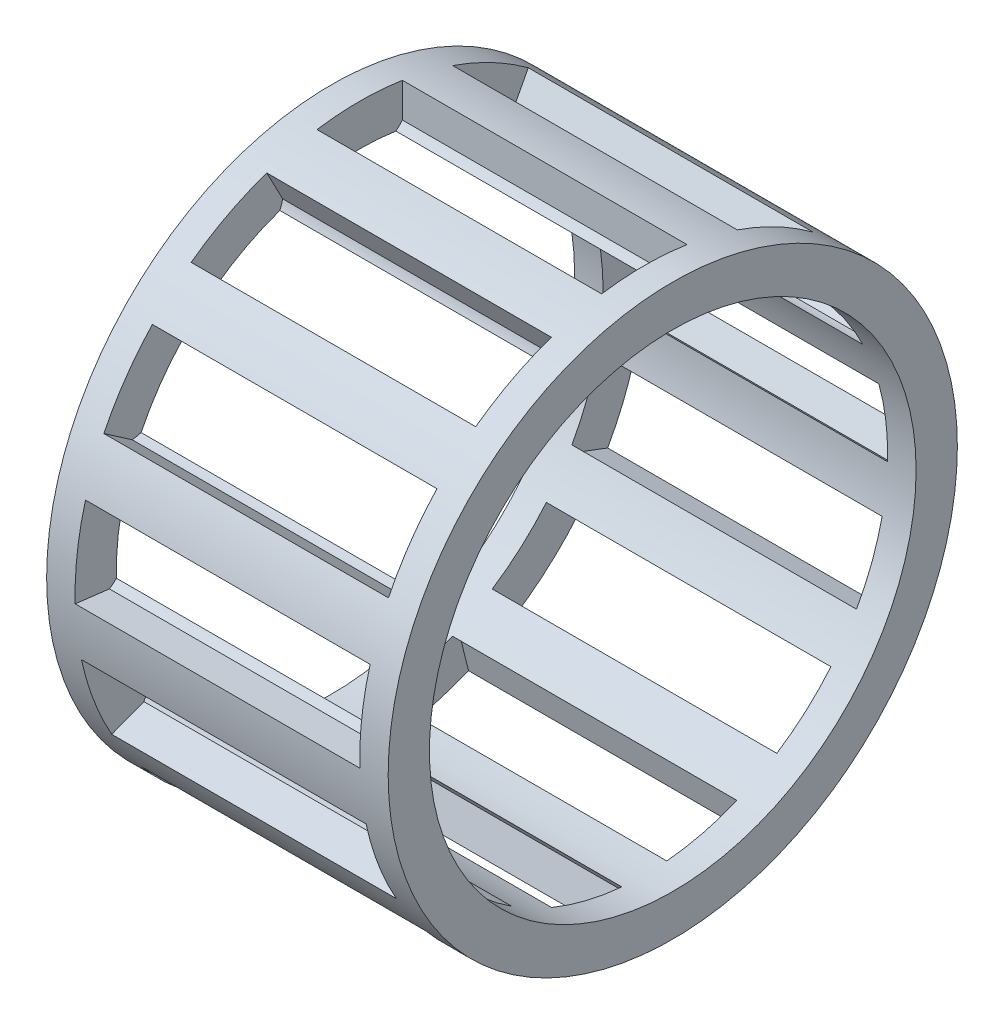
from build123d import *

# Parameters (mm, degrees)
SCHIZZO4_W                  = 12
SCHIZZO4_H                  = 1.45
TAGLIO_ESTRUSIONE1_DEPTH    = 5
RIPETIZIONECIRCOLARE1_COUNT = 13


with BuildPart() as part:
    # Schizzo4 → Rivoluzione1 (revolve)
    with BuildSketch(Plane.XY):
        with Locations((0, 9.275)):
            Rectangle(SCHIZZO4_W, SCHIZZO4_H)
    revolve(axis=Axis((0, 0, 0), (-1, 0, 0)))

    # Schizzo6 → Taglio-Estrusione1 (cut, symmetric)
    with BuildSketch(Plane(origin=(0, 0, 0), x_dir=(0, 0, -1), z_dir=(1, 0, 0))):
        with BuildLine():
            Line((-1.5, 10), (-1.5, 8.677124344))
            ThreePointArc((-1.5, 8.677124344), (0, 8), (1.5, 8.677124344))
            Line((1.5, 8.677124344), (1.5, 10))
            ThreePointArc((1.5, 10), (0, 11.5), (-1.5, 10))
        make_face()
    taglio_estrusione1 = extrude(amount=TAGLIO_ESTRUSIONE1_DEPTH, both=True, mode=Mode.SUBTRACT)

    # RipetizioneCircolare1: Taglio-Estrusione1 ×13 about axis
    ripetizionecircolare1_axis = Axis((0, 0, 0), (1, 0, 0))
    for i in range(1, RIPETIZIONECIRCOLARE1_COUNT):
        add(taglio_estrusione1.rotate(ripetizionecircolare1_axis, i * 360 / RIPETIZIONECIRCOLARE1_COUNT), mode=Mode.SUBTRACT)


solid = part.part
